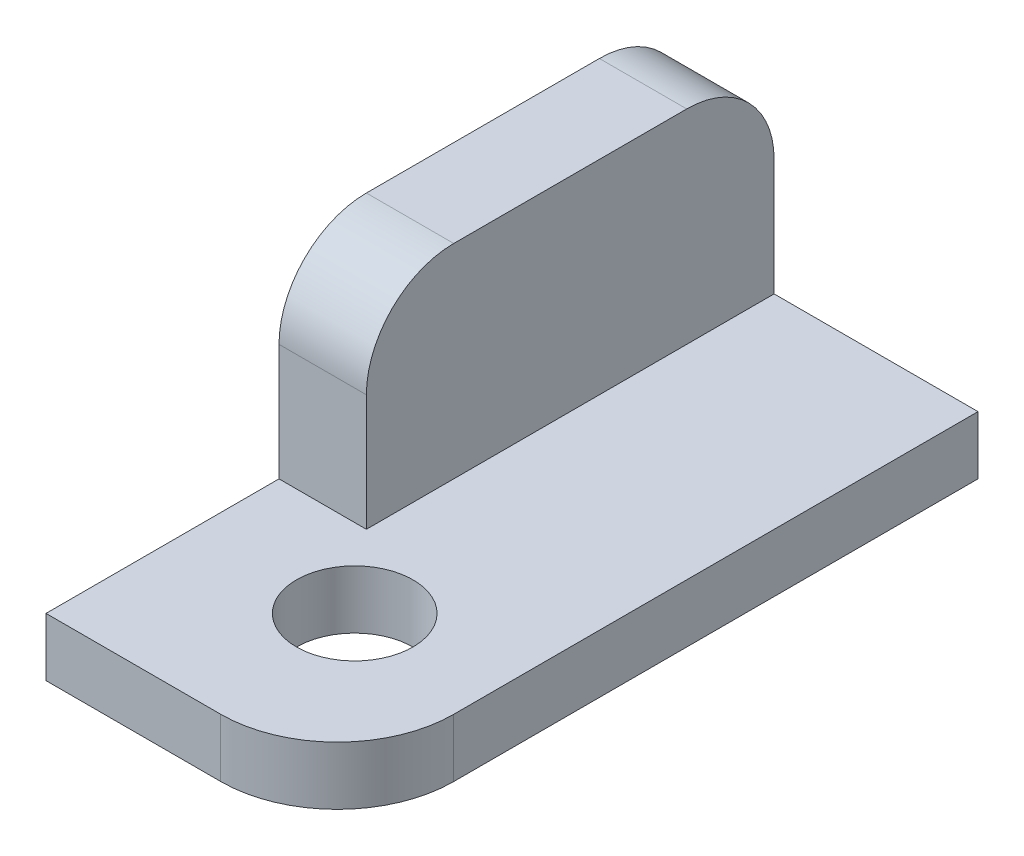
from build123d import *

# Parameters (mm, degrees)
EXTRUDE_1_DEPTH     = 50
SKETCH_2_W          = 35
SKETCH_2_H          = 35
CUT_EXTRUDE_1_DEPTH = 116
FILLET_1_R          = 15
SKETCH_3_R          = 10
CUT_EXTRUDE_2_DEPTH = 10
FILLET_2_R          = 20


with BuildPart() as part:
    # 스케치1 → 보스-돌출1 (new body)
    with BuildSketch(Plane(origin=(0, 0, 0), x_dir=(0, 0, -1), z_dir=(1, 0, 0))):
        Polygon((0, 0), (40, 0), (40, 35), (110, 35), (110, -10), (0, -10), align=None)
    extrude(amount=EXTRUDE_1_DEPTH)

    # 스케치2 → 컷-돌출1 (cut)
    with BuildSketch(Plane.XY.offset(-40)):
        with Locations((32.5, 17.5)):
            Rectangle(SKETCH_2_W, SKETCH_2_H)
    extrude(amount=-CUT_EXTRUDE_1_DEPTH, mode=Mode.SUBTRACT)

    # 필렛1
    fillet_1_edges = [part.edges().sort_by_distance(p)[0] for p in [
        (7.5, 35, -40),
        (7.5, 35, -110),
    ]]
    fillet(fillet_1_edges, radius=FILLET_1_R)

    # 스케치3 → 컷-돌출2 (cut)
    with BuildSketch(Plane(origin=(0, 0, 0), x_dir=(1, 0, 0), z_dir=(0, 1, 0))):
        with Locations((26.5, 26.5)):
            Circle(SKETCH_3_R)
    extrude(amount=-CUT_EXTRUDE_2_DEPTH, mode=Mode.SUBTRACT)

    # 필렛2
    fillet_2_edges = [part.edges().sort_by_distance(p)[0] for p in [
        (50, -5, 0),
    ]]
    fillet(fillet_2_edges, radius=FILLET_2_R)


solid = part.part
